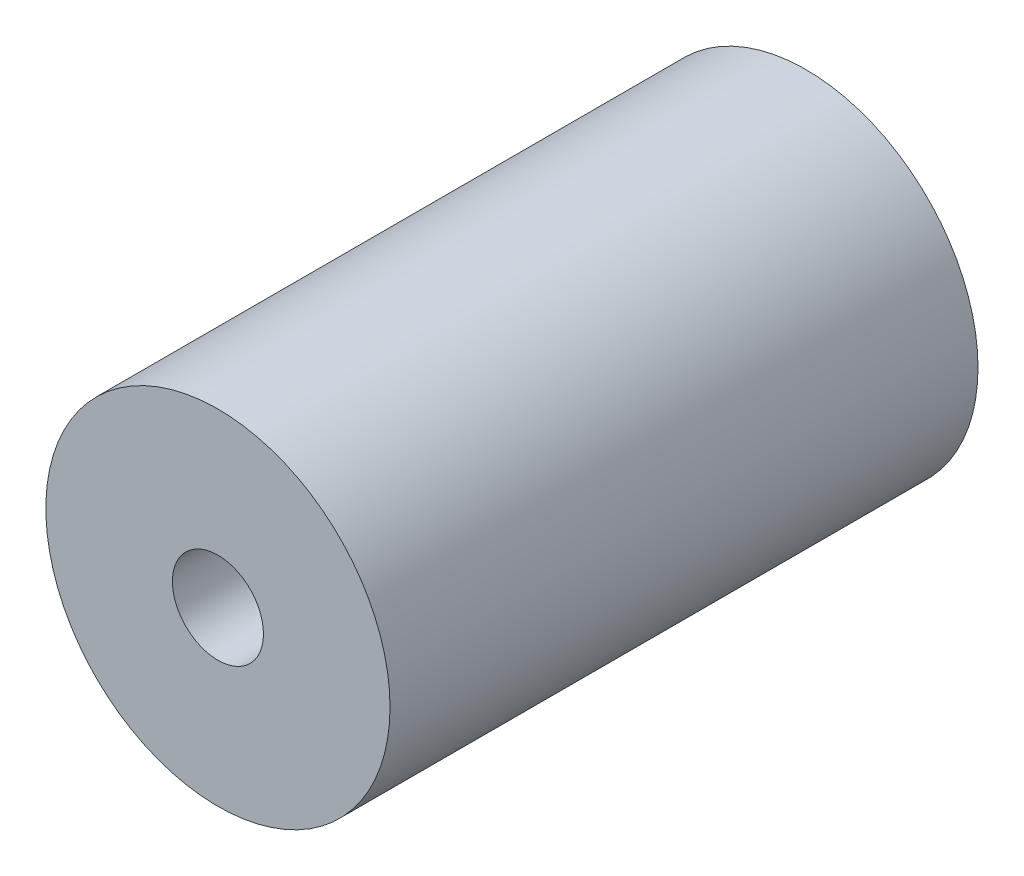
from build123d import *

# Parameters (mm, degrees)
SKETCH1_R                = 6
SKETCH1_R_2              = 1.5875
BOSS_EXTRUDE1_DEPTH      = 10.5
BOSS_EXTRUDE1_DEPTH_BACK = 10


with BuildPart() as part:
    # Sketch1 → Boss-Extrude1 (new body, two sides)
    with BuildSketch(Plane.XY) as boss_extrude1_sk:
        with Locations((-4.378147327, 5.74503364)):
            Circle(SKETCH1_R)
        with Locations((-4.378147327, 5.74503364)):
            Circle(SKETCH1_R_2, mode=Mode.SUBTRACT)
    extrude(amount=BOSS_EXTRUDE1_DEPTH)
    extrude(boss_extrude1_sk.sketch, amount=-BOSS_EXTRUDE1_DEPTH_BACK)


solid = part.part
